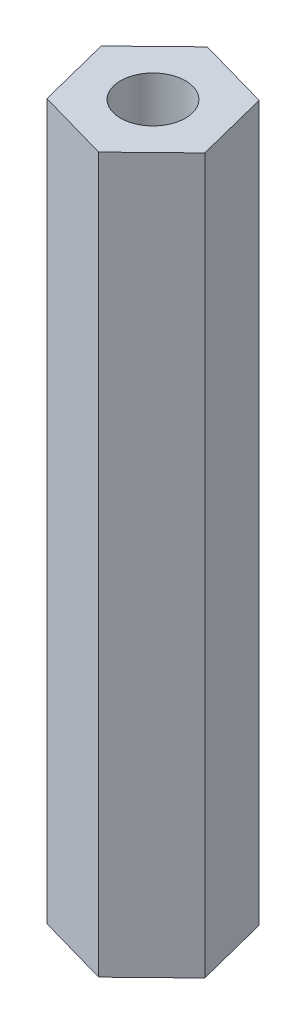
from build123d import *

# Parameters (mm, degrees)
SKETCH1_R           = 1.5875
BOSS_EXTRUDE1_DEPTH = 34.925


with BuildPart() as part:
    # Sketch1 → Boss-Extrude1 (new body)
    with BuildSketch(Plane(origin=(0, 0, 0), x_dir=(1, 0, 0), z_dir=(0, 1, 0))):
        Polygon((2.628181325, 2.556070472), (-0.8995313, 3.554107029), (-3.527712625, 0.998036557), (-2.628181325, -2.556070472), (0.8995313, -3.554107029), (3.527712625, -0.998036557), align=None)
        Circle(SKETCH1_R, mode=Mode.SUBTRACT)
    extrude(amount=BOSS_EXTRUDE1_DEPTH)


solid = part.part
